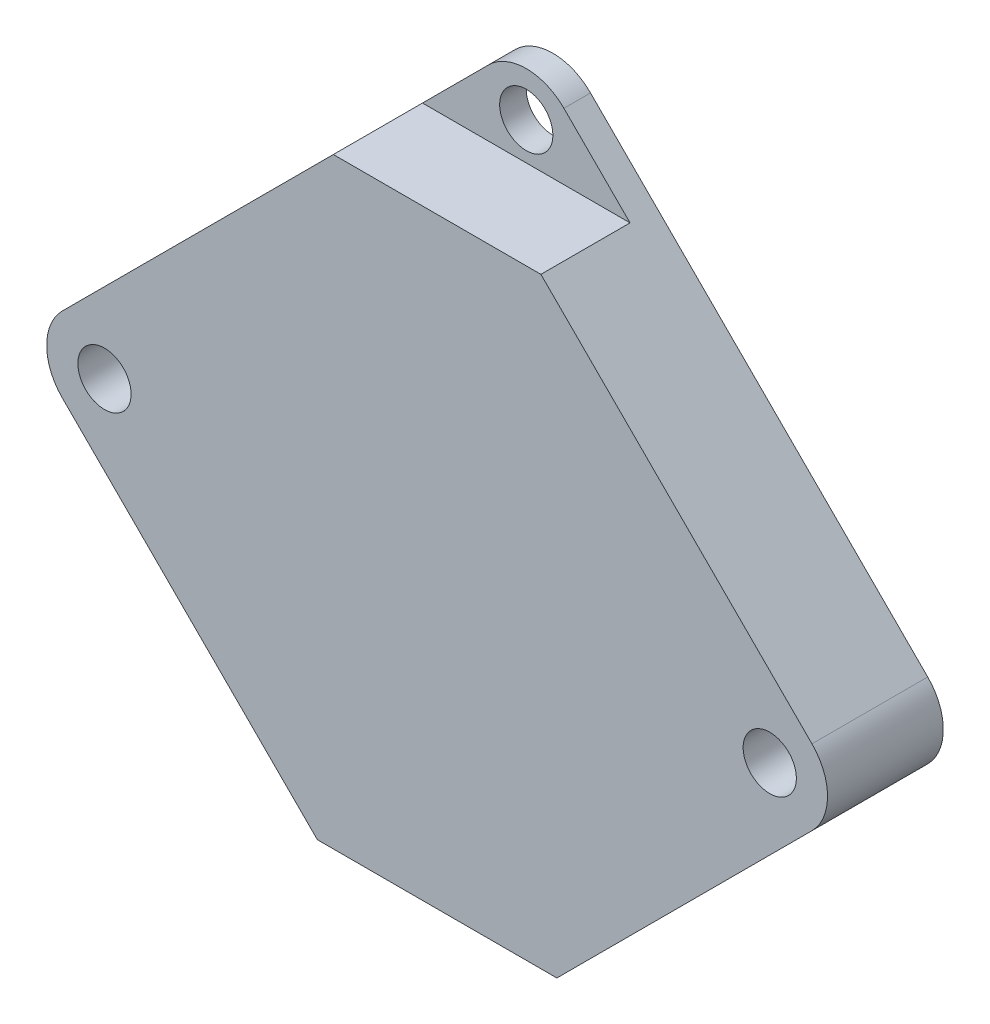
from build123d import *

# Parameters (mm, degrees)
BOSS_EXTRUDE1_DEPTH = 4.35
SKETCH1_3_R         = 1
CUT_EXTRUDE1_DEPTH  = 5.35
SKETCH1_4_R         = 10
SKETCH1_4_R_2       = 4.1
CUT_EXTRUDE2_DEPTH  = 2
FILLET1_R           = 2
CUT_EXTRUDE3_DEPTH  = 5.35
CUT_EXTRUDE4_DEPTH  = 21.2
CUT_EXTRUDE5_DEPTH  = 3.35


with BuildPart() as part:
    # Sketch1 → Boss-Extrude1 (new body)
    with BuildSketch(Plane.XY):
        Polygon((0, 15.5), (-15.5, 0), (0, -15.5), (15.5, 0), align=None)
    extrude(amount=BOSS_EXTRUDE1_DEPTH)

    # Sketch1_3 → Cut-Extrude1 (cut, through all)
    with BuildSketch(Plane.XY):
        with Locations((-12.5, 0)):
            Circle(SKETCH1_3_R)
        with Locations((12.5, 0)):
            Circle(SKETCH1_3_R)
        with Locations((0, 13)):
            Circle(SKETCH1_3_R)
    extrude(amount=CUT_EXTRUDE1_DEPTH, mode=Mode.SUBTRACT)

    # Sketch1_4 → Cut-Extrude2 (cut)
    with BuildSketch(Plane.XY):
        Circle(SKETCH1_4_R)
        with Locations((0, 7)):
            Circle(SKETCH1_4_R_2)
    extrude(amount=CUT_EXTRUDE2_DEPTH, mode=Mode.SUBTRACT)

    # Fillet1
    fillet1_edges = [part.edges().sort_by_distance(p)[0] for p in [
        (0, -15.5, 2.175),
        (-15.5, 0, 2.175),
        (0, 15.5, 2.175),
        (15.5, 0, 2.175),
    ]]
    fillet(fillet1_edges, radius=FILLET1_R)

    # Sketch2 → Cut-Extrude3 (cut, through all)
    with BuildSketch(Plane(origin=(0, 0, 0), x_dir=(-1, 0, 0), z_dir=(0, 0, -1))):
        with BuildLine():
            Line((4.5, -11), (-4.5, -11))
            Line((-4.5, -11), (-1.414213562, -14.085786438))
            ThreePointArc((-1.414213562, -14.085786438), (0, -14.671572875), (1.414213562, -14.085786438))
            Line((1.414213562, -14.085786438), (4.5, -11))
        make_face()
    extrude(amount=-CUT_EXTRUDE3_DEPTH, mode=Mode.SUBTRACT)

    # Sketch4 → Cut-Extrude4 (cut)
    with BuildSketch(Plane.XZ.offset(11)):
        with BuildLine():
            Line((-1, 2.7), (1, 2.7))
            ThreePointArc((1, 2.7), (1.7, 2), (1, 1.3))
            Line((1, 1.3), (-1, 1.3))
            ThreePointArc((-1, 1.3), (-1.7, 2), (-1, 2.7))
        make_face()
    extrude(amount=-CUT_EXTRUDE4_DEPTH, mode=Mode.SUBTRACT)

    # Sketch11 → Cut-Extrude5 (cut)
    with BuildSketch(Plane.XY.offset(4.35)):
        Polygon((-3.9, 11.6), (3.9, 11.6), (0, 15.5), align=None)
    extrude(amount=-CUT_EXTRUDE5_DEPTH, mode=Mode.SUBTRACT)


solid = part.part
